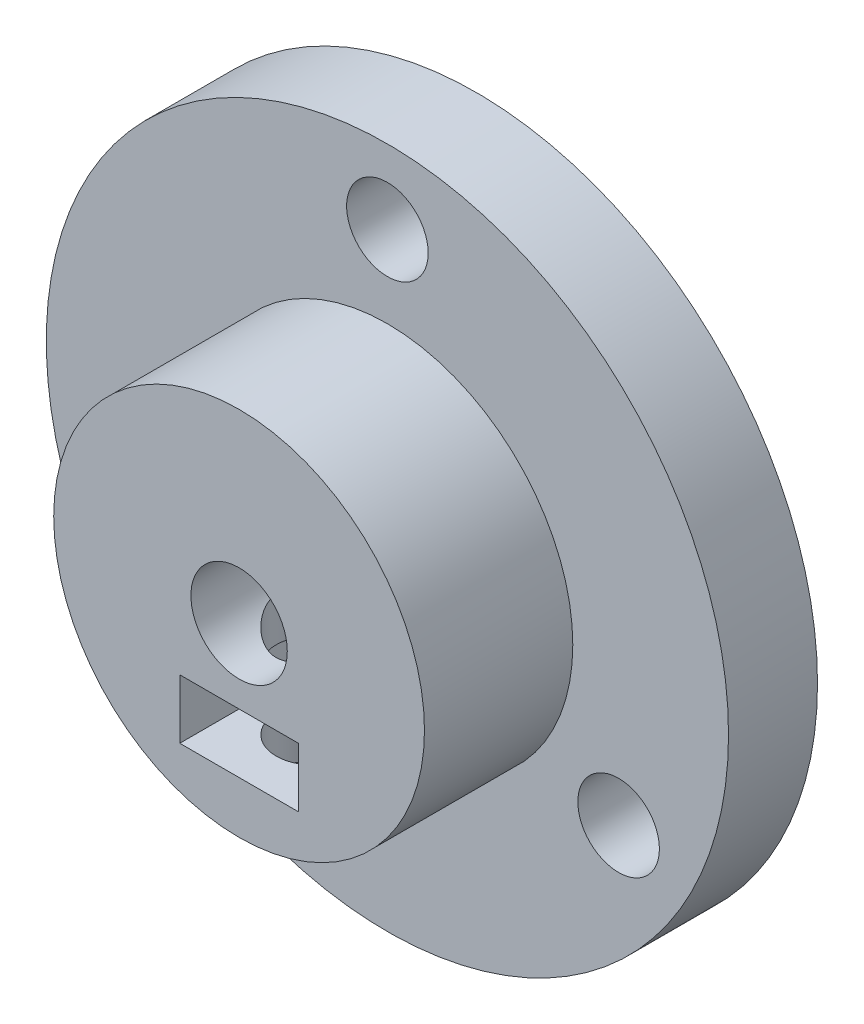
from build123d import *

# Parameters (mm, degrees)
ESQUISSE1_R                  = 23
BOSS_EXTRU_1_DEPTH           = 6
ESQUISSE2_R                  = 12.5
BOSS_EXTRU_2_DEPTH           = 10
ESQUISSE3_R                  = 3.25
ENL_V_MAT_EXTRU_1_DEPTH      = 16
ENL_V_MAT_EXTRU_2_REACH      = 38.249
ENL_V_MAT_EXTRU_2_END_RADIUS = 12.5
ESQUISSE4_R                  = 2.5
ESQUISSE5_R                  = 2.75
ENL_V_MAT_EXTRU_3_DEPTH      = 6
R_P_T_PAR_COURBE1_COUNT      = 3
ENL_V_MAT_EXTRU_4_REACH      = 38.249
ESQUISSE6_W                  = 8
ESQUISSE6_H                  = 4


with BuildPart() as part:
    # Esquisse1 → Boss.-Extru.1 (new body)
    with BuildSketch(Plane.XY):
        Circle(ESQUISSE1_R)
    extrude(amount=BOSS_EXTRU_1_DEPTH)

    # Esquisse2 → Boss.-Extru.2 (add)
    with BuildSketch(Plane.XY.offset(6)):
        Circle(ESQUISSE2_R)
    extrude(amount=BOSS_EXTRU_2_DEPTH)

    # Esquisse3 → Enlèv. mat.-Extru.1 (cut)
    with BuildSketch(Plane.XY.offset(16)):
        Circle(ESQUISSE3_R)
    extrude(amount=-ENL_V_MAT_EXTRU_1_DEPTH, mode=Mode.SUBTRACT)

    # Enlèv. mat.-Extru.2: up to this cylinder (the profile starts inside it)
    enl_v_mat_extru_2_end = Plane(origin=(0, 0, 11), z_dir=(0, 0, -1)) * Cylinder(ENL_V_MAT_EXTRU_2_END_RADIUS, 102.498, mode=Mode.PRIVATE)
    # Esquisse4 → Enlèv. mat.-Extru.2 (cut, up to the surface)
    with BuildSketch(Plane(origin=(0, 0, 0), x_dir=(1, 0, 0), z_dir=(0, 1, 0)), mode=Mode.PRIVATE) as enl_v_mat_extru_2_sk1:
        with Locations(Location((0, -11, 0), (0, 0, 270))):
            Circle(ESQUISSE4_R)
    enl_v_mat_extru_2_tool1 = extrude(enl_v_mat_extru_2_sk1.sketch, amount=-ENL_V_MAT_EXTRU_2_REACH, mode=Mode.PRIVATE) & enl_v_mat_extru_2_end
    add(enl_v_mat_extru_2_tool1.solids().sort_by_distance((0, 0, 11))[0], mode=Mode.SUBTRACT)

    # Esquisse5 → Enlèv. mat.-Extru.3 (cut)
    with BuildSketch(Plane.XY.offset(6)):
        with Locations((0, 18)):
            Circle(ESQUISSE5_R)
    enl_v_mat_extru_3 = extrude(amount=-ENL_V_MAT_EXTRU_3_DEPTH, mode=Mode.SUBTRACT)

    # Répét. par courbe1: Enlèv. mat.-Extru.3 ×3 about axis
    r_p_t_par_courbe1_axis = Axis((0, 0, 6), (0, 0, -1))
    for i in range(1, R_P_T_PAR_COURBE1_COUNT):
        add(enl_v_mat_extru_3.rotate(r_p_t_par_courbe1_axis, i * 360 / R_P_T_PAR_COURBE1_COUNT), mode=Mode.SUBTRACT)

    # Enlèv. mat.-Extru.4: up to this face of the body (flat: up to its plane)
    enl_v_mat_extru_4_end = Plane(part.part.faces().sort_by_distance((-22.349461761, 0, 6))[0])
    # Esquisse6 → Enlèv. mat.-Extru.4 (cut, up to the picked face)
    with BuildSketch(Plane.XY.offset(16), mode=Mode.PRIVATE) as enl_v_mat_extru_4_sk1:
        with Locations((0, -7)):
            Rectangle(ESQUISSE6_W, ESQUISSE6_H)
    enl_v_mat_extru_4_tool1 = split(extrude(enl_v_mat_extru_4_sk1.sketch, amount=-ENL_V_MAT_EXTRU_4_REACH, mode=Mode.PRIVATE), bisect_by=enl_v_mat_extru_4_end, keep=Keep.BOTH, mode=Mode.PRIVATE)
    add(enl_v_mat_extru_4_tool1.solids().sort_by(Axis((0, -7, 16), (0, 0, -1)))[0], mode=Mode.SUBTRACT)


solid = part.part
